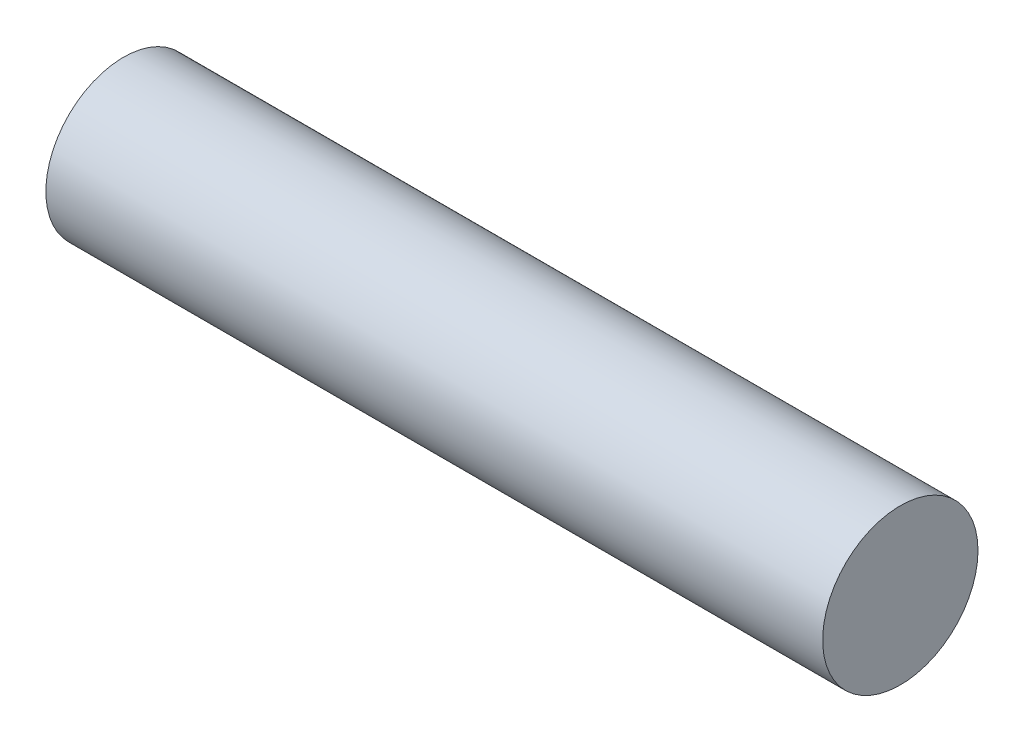
from build123d import *

# Parameters (mm, degrees)
RIVETPROFILE_R      = 40
BOSS_EXTRUDE1_DEPTH = 400


with BuildPart() as part:
    # RivetProfile → Boss-Extrude1 (new body)
    with BuildSketch(Plane(origin=(0, 0, 0), x_dir=(0, 0, -1), z_dir=(1, 0, 0))):
        Circle(RIVETPROFILE_R)
    extrude(amount=BOSS_EXTRUDE1_DEPTH)


solid = part.part
